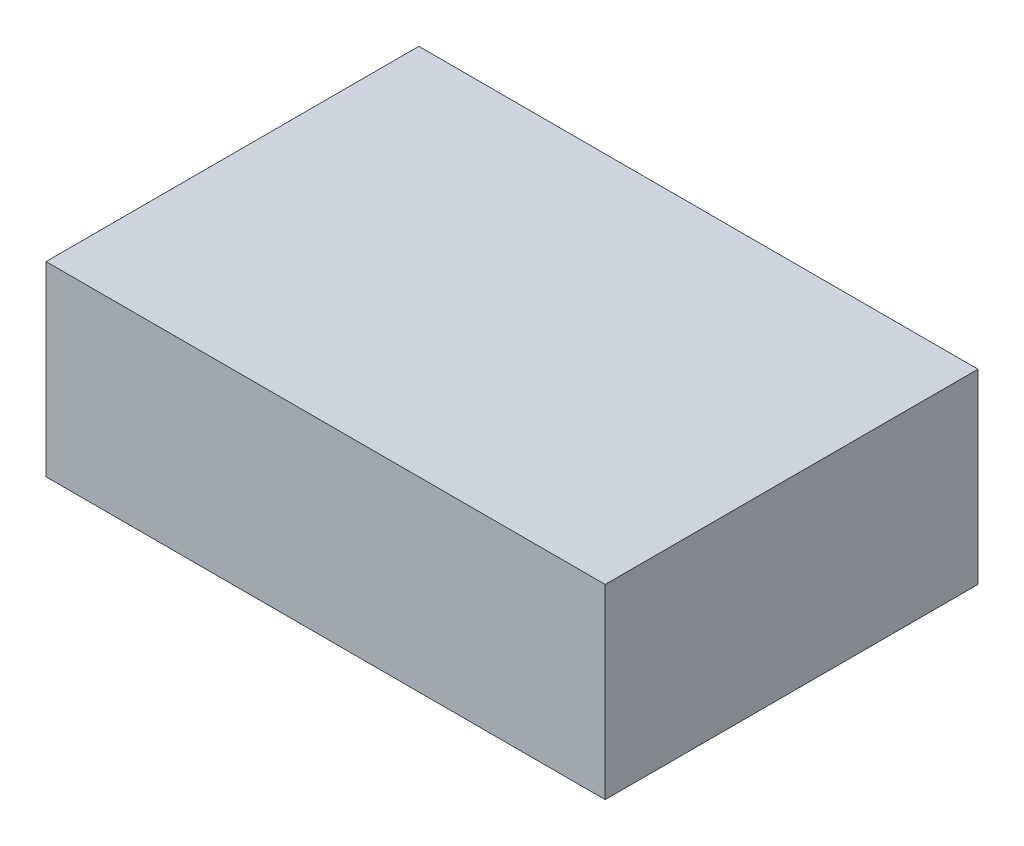
from build123d import *

# Parameters (mm, degrees)
ESQUISSE1_W        = 90
ESQUISSE1_H        = 60
BOSS_EXTRU_1_DEPTH = 30


with BuildPart() as part:
    # Esquisse1 → Boss.-Extru.1 (new body)
    with BuildSketch(Plane(origin=(0, 0, 0), x_dir=(1, 0, 0), z_dir=(0, 1, 0))):
        Rectangle(ESQUISSE1_W, ESQUISSE1_H)
    extrude(amount=BOSS_EXTRU_1_DEPTH)


solid = part.part
